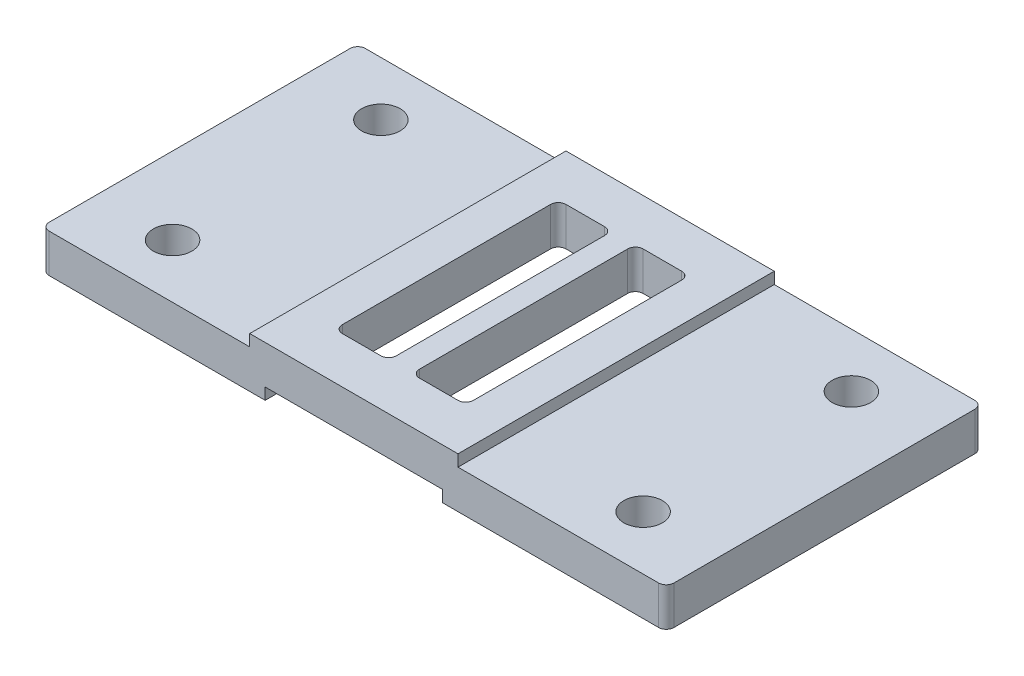
from build123d import *

# Parameters (mm, degrees)
SKETCH1_W                   = 162
SKETCH1_H                   = 82
BOSS_EXTRUDE1_DEPTH         = 13
SKETCH2_W                   = 54
SKETCH2_H                   = 3
CUT_EXTRUDE1_DEPTH          = 83
SKETCH3_W                   = 54
SKETCH3_H                   = 3
CUT_EXTRUDE2_DEPTH          = 83
SKETCH4_W                   = 46
SKETCH4_H                   = 3
CUT_EXTRUDE3_DEPTH          = 83
SKETCH5_W                   = 14
SKETCH5_H                   = 58
CUT_EXTRUDE4_DEPTH          = 11
SKETCH6_W                   = 14
SKETCH6_H                   = 58
CUT_EXTRUDE5_DEPTH          = 14
F_3_8_CLEARANCE_HOLE1_D     = 10
F_3_8_CLEARANCE_HOLE1_DEPTH = 10
FILLET1_R                   = 2


with BuildPart() as part:
    # Sketch1 → Boss-Extrude1 (new body)
    with BuildSketch(Plane(origin=(0, 8, 0), x_dir=(1, 0, 0), z_dir=(0, 1, 0))):
        Rectangle(SKETCH1_W, SKETCH1_H)
    extrude(amount=-BOSS_EXTRUDE1_DEPTH)

    # Sketch2 → Cut-Extrude1 (cut, through all)
    with BuildSketch(Plane(origin=(0, 0, -41), x_dir=(-1, 0, 0), z_dir=(0, 0, -1))):
        with Locations((-54, 6.5)):
            Rectangle(SKETCH2_W, SKETCH2_H)
    extrude(amount=-CUT_EXTRUDE1_DEPTH, mode=Mode.SUBTRACT)

    # Sketch3 → Cut-Extrude2 (cut, through all)
    with BuildSketch(Plane(origin=(0, 0, -41), x_dir=(-1, 0, 0), z_dir=(0, 0, -1))):
        with Locations((54, 6.5)):
            Rectangle(SKETCH3_W, SKETCH3_H)
    extrude(amount=-CUT_EXTRUDE2_DEPTH, mode=Mode.SUBTRACT)

    # Sketch4 → Cut-Extrude3 (cut, through all)
    with BuildSketch(Plane(origin=(0, 0, -41), x_dir=(-1, 0, 0), z_dir=(0, 0, -1))):
        with Locations((0, -3.5)):
            Rectangle(SKETCH4_W, SKETCH4_H)
    extrude(amount=-CUT_EXTRUDE3_DEPTH, mode=Mode.SUBTRACT)

    # Sketch5 → Cut-Extrude4 (cut, through all)
    with BuildSketch(Plane.XZ.offset(2)):
        with Locations((-10, 0)):
            Rectangle(SKETCH5_W, SKETCH5_H)
    extrude(amount=-CUT_EXTRUDE4_DEPTH, mode=Mode.SUBTRACT)

    # Sketch6 → Cut-Extrude5 (cut, through all)
    with BuildSketch(Plane(origin=(0, 8, 0), x_dir=(-1, 0, 0), z_dir=(0, 1, 0))):
        with Locations((-10, 0)):
            Rectangle(SKETCH6_W, SKETCH6_H)
    extrude(amount=-CUT_EXTRUDE5_DEPTH, mode=Mode.SUBTRACT)

    # 3/8 Clearance Hole1
    with Locations(Plane(origin=(0, 5, 0), x_dir=(1, 0, 0), z_dir=(0, 1, 0))):
        with Locations((-61, 27), (61, 27), (-61, -27), (61, -27)):
            Hole(F_3_8_CLEARANCE_HOLE1_D / 2, depth=F_3_8_CLEARANCE_HOLE1_DEPTH)

    # Fillet1
    fillet1_edges = [part.edges().sort_by_distance(p)[0] for p in [
        (-3, 3, 29),
        (-3, 3, -29),
        (-17, 3, -29),
        (-17, 3, 29),
        (3, 3, -29),
        (81, 0, 41),
        (17, 3, -29),
        (17, 3, 29),
        (3, 3, 29),
        (-81, 0, 41),
        (-81, 0, -41),
        (81, 0, -41),
    ]]
    fillet(fillet1_edges, radius=FILLET1_R)


solid = part.part
